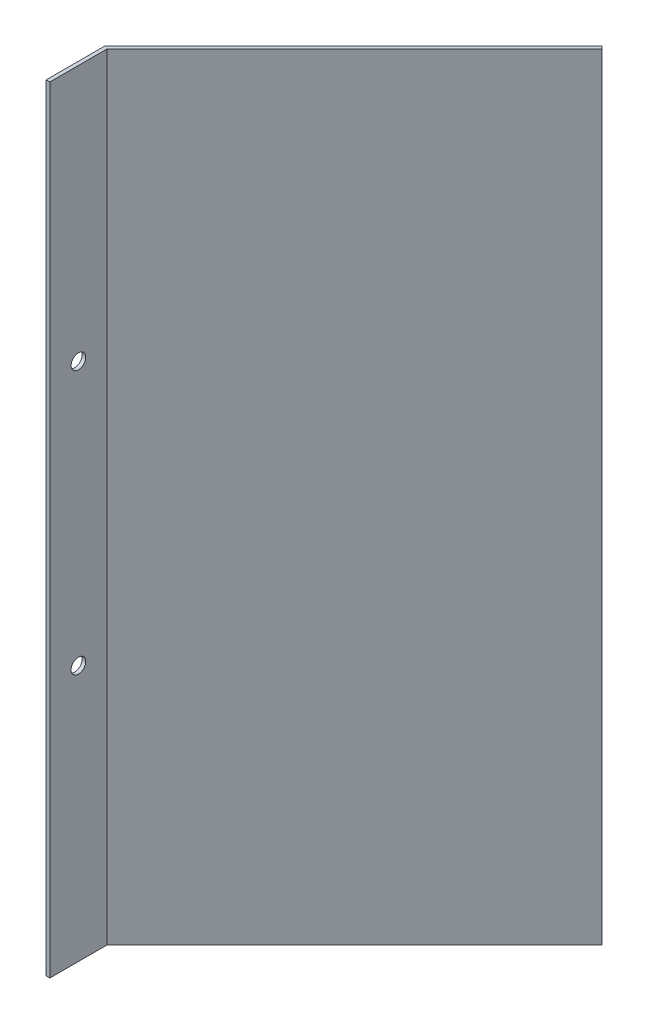
from build123d import *

# Parameters (mm, degrees)
BOSS_EXTRUDE1_DEPTH = 673.1
SKETCH2_R           = 6.35
CUT_EXTRUDE1_DEPTH  = 4.175


with BuildPart() as part:
    # Sketch1 → Boss-Extrude1 (new body)
    with BuildSketch(Plane(origin=(0, 0, 0), x_dir=(1, 0, 0), z_dir=(0, 1, 0))):
        Polygon((0, 0), (0, 50.8), (215.526146906, 266.326146906), (217.771210936, 264.081082875), (3.175, 49.484871939), (3.175, 0), align=None)
    extrude(amount=BOSS_EXTRUDE1_DEPTH)

    # Sketch2 → Cut-Extrude1 (cut, through all)
    with BuildSketch(Plane(origin=(3.175, 0, 0), x_dir=(0, 0, -1), z_dir=(1, 0, 0))):
        with Locations((24.74243597, 450.85)):
            Circle(SKETCH2_R)
        with Locations((24.74243597, 222.25)):
            Circle(SKETCH2_R)
    extrude(amount=-CUT_EXTRUDE1_DEPTH, mode=Mode.SUBTRACT)


solid = part.part
